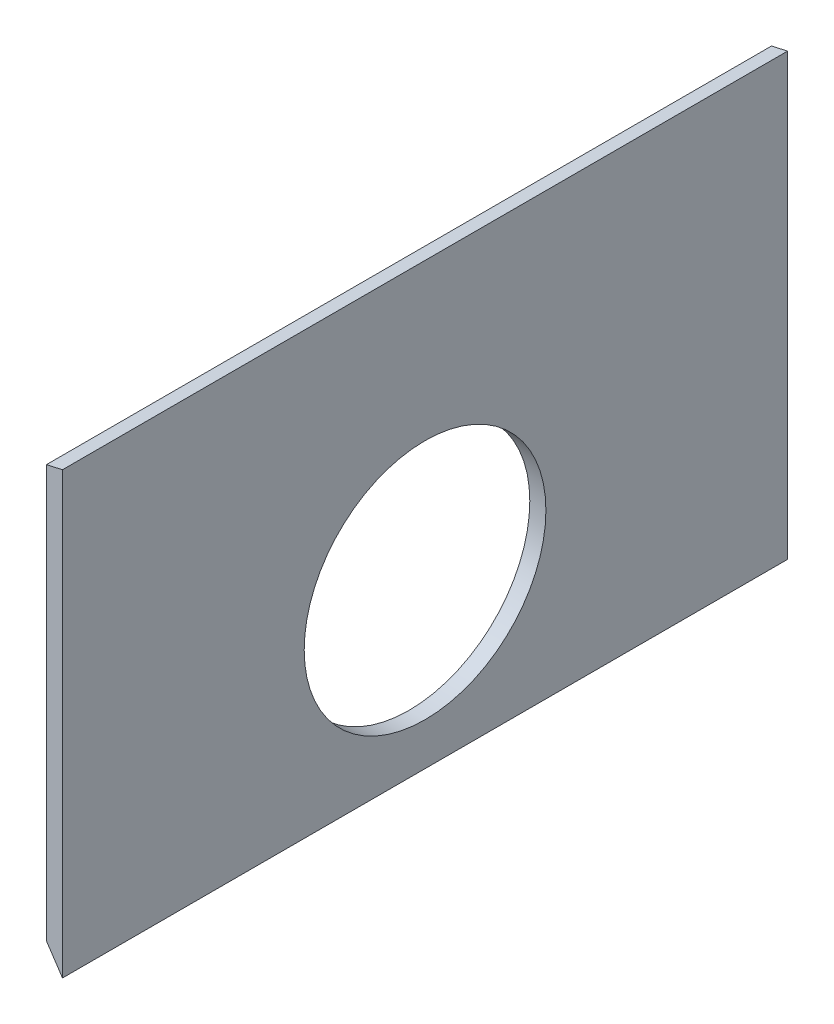
from build123d import *

# Parameters (mm, degrees)
AUFSATZ_LINEAR_AUSTRAGEN1_DEPTH  = 450
F_15_0_15_DURCHMESSER_BOHRUNG1_D = 150


with BuildPart() as part:
    # Skizze1 → Aufsatz-Linear austragen1 (new body)
    with BuildSketch(Plane.XY):
        Polygon((331.858259494, 76.52367356), (341.858259494, 78.794563683), (341.858259494, -194.367647059), (331.858259494, -179.367647059), align=None)
    extrude(amount=AUFSATZ_LINEAR_AUSTRAGEN1_DEPTH)

    # Ø15.0 (15) Durchmesser Bohrung1 (through all)
    with Locations(Plane(origin=(331.858259494, -93.067647059, 225), x_dir=(0, -1, 0), z_dir=(-1, 0, 0))):
        with Locations((0, 0)):
            Hole(F_15_0_15_DURCHMESSER_BOHRUNG1_D / 2)


solid = part.part
